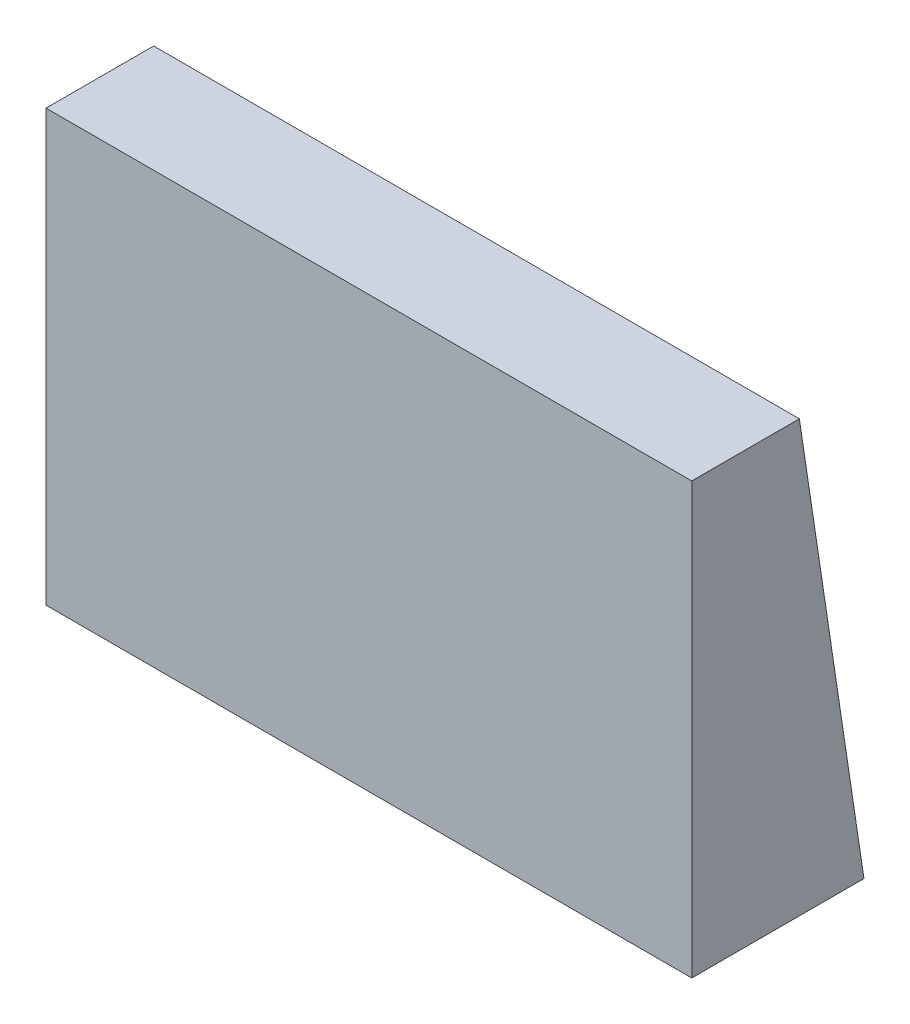
from build123d import *

# Parameters (mm, degrees)
SKETCH1_W           = 30
SKETCH1_H           = 5
BOSS_EXTRUDE1_DEPTH = 20
BOSS_EXTRUDE2_DEPTH = 30


with BuildPart() as part:
    # Sketch1 → Boss-Extrude1 (new body)
    with BuildSketch(Plane(origin=(0, 0, 0), x_dir=(1, 0, 0), z_dir=(0, 1, 0))):
        Rectangle(SKETCH1_W, SKETCH1_H)
    extrude(amount=BOSS_EXTRUDE1_DEPTH)

    # Sketch2 → Boss-Extrude2 (add)
    with BuildSketch(Plane(origin=(15, 0, 0), x_dir=(0, 0, -1), z_dir=(1, 0, 0))):
        Polygon((2.5, 0), (5.5, 0), (2.5, 20), align=None)
    extrude(amount=-BOSS_EXTRUDE2_DEPTH)


solid = part.part
